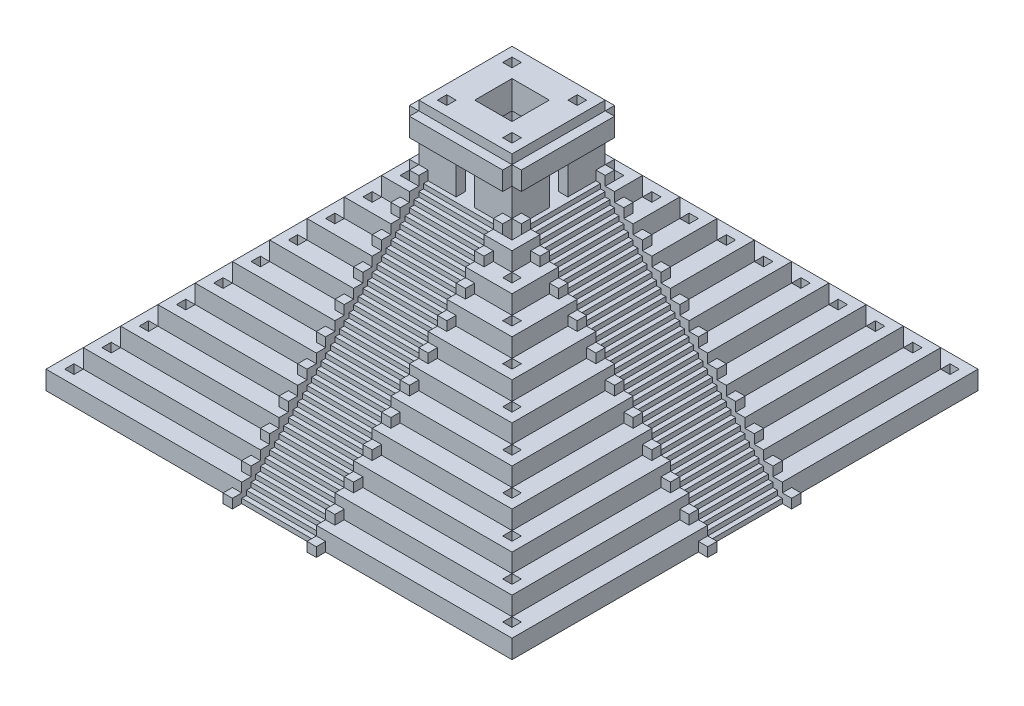
from build123d import *

# Parameters (mm, degrees)
SKIZZE1_W                        = 50
SKIZZE1_H                        = 50
SKIZZE1_W_2                      = 40
SKIZZE1_H_2                      = 40
AUFSATZ_LINEAR_AUSTRAGEN1_DEPTH  = 2
SKIZZE2_W                        = 46
SKIZZE2_H                        = 46
SKIZZE2_W_2                      = 36
SKIZZE2_H_2                      = 36
AUFSATZ_LINEAR_AUSTRAGEN2_DEPTH  = 2
SKIZZE3_W                        = 42
SKIZZE3_H                        = 42
SKIZZE3_W_2                      = 32
SKIZZE3_H_2                      = 32
AUFSATZ_LINEAR_AUSTRAGEN3_DEPTH  = 2
SKIZZE4_W                        = 38
SKIZZE4_H                        = 38
SKIZZE4_W_2                      = 28
SKIZZE4_H_2                      = 28
AUFSATZ_LINEAR_AUSTRAGEN4_DEPTH  = 2
SKIZZE5_W                        = 34
SKIZZE5_H                        = 34
SKIZZE5_W_2                      = 24
SKIZZE5_H_2                      = 24
AUFSATZ_LINEAR_AUSTRAGEN5_DEPTH  = 2
SKIZZE6_W                        = 30
SKIZZE6_H                        = 30
SKIZZE6_W_2                      = 20
SKIZZE6_H_2                      = 20
AUFSATZ_LINEAR_AUSTRAGEN6_DEPTH  = 2
SKIZZE7_W                        = 26
SKIZZE7_H                        = 26
SKIZZE7_W_2                      = 16
SKIZZE7_H_2                      = 16
AUFSATZ_LINEAR_AUSTRAGEN7_DEPTH  = 2
SKIZZE8_W                        = 22
SKIZZE8_H                        = 22
SKIZZE8_W_2                      = 12
SKIZZE8_H_2                      = 12
AUFSATZ_LINEAR_AUSTRAGEN8_DEPTH  = 2
SKIZZE9_W                        = 18
SKIZZE9_H                        = 18
SKIZZE9_W_2                      = 8
SKIZZE9_H_2                      = 8
AUFSATZ_LINEAR_AUSTRAGEN9_DEPTH  = 2
SKIZZE10_W                       = 14
SKIZZE10_H                       = 14
SKIZZE10_W_2                     = 4
SKIZZE10_H_2                     = 4
AUFSATZ_LINEAR_AUSTRAGEN10_DEPTH = 2
AUFSATZ_LINEAR_AUSTRAGEN11_DEPTH = 4
SKIZZE13_W                       = 12
SKIZZE13_H                       = 12
SKIZZE13_W_2                     = 4
SKIZZE13_H_2                     = 4
AUFSATZ_LINEAR_AUSTRAGEN12_DEPTH = 2
SKIZZE13_3_W                     = 10
SKIZZE13_3_H                     = 10
SKIZZE13_3_W_2                   = 4
SKIZZE13_3_H_2                   = 4
AUFSATZ_LINEAR_AUSTRAGEN13_DEPTH = 3
SKIZZE11_W                       = 1
SKIZZE11_H                       = 1
SCHNITT_LINEAR_AUSTRAGEN1_DEPTH  = 45.485952839
AUFSATZ_LINEAR_START             = 4
SKIZZE14_W                       = 1
SKIZZE14_H                       = 1
AUFSATZ_LINEAR_AUSTRAGEN14_DEPTH = 1
SCHNITT_LINEAR_AUSTRAGEN2_DEPTH  = 4
KREISMUSTER1_COUNT               = 4
KREISMUSTER1_START               = 4
KREISMUSTER1_COPY_1_SKETCH_W     = 1
KREISMUSTER1_COPY_1_SKETCH_H     = 1
KREISMUSTER1_COPY_1_DEPTH        = 1
KREISMUSTER1_COPY_2_SKETCH_W     = 1
KREISMUSTER1_COPY_2_SKETCH_H     = 1
KREISMUSTER1_COPY_2_DEPTH        = 1
KREISMUSTER1_COPY_3_SKETCH_W     = 1
KREISMUSTER1_COPY_3_SKETCH_H     = 1
KREISMUSTER1_COPY_3_DEPTH        = 1


with BuildPart() as part:
    # Skizze1 → Aufsatz-Linear austragen1 (new body)
    with BuildSketch(Plane(origin=(0, 0, 0), x_dir=(1, 0, 0), z_dir=(0, 1, 0))):
        Rectangle(SKIZZE1_W, SKIZZE1_H)
        Rectangle(SKIZZE1_W_2, SKIZZE1_H_2, mode=Mode.SUBTRACT)
    extrude(amount=AUFSATZ_LINEAR_AUSTRAGEN1_DEPTH)

    # Skizze2 → Aufsatz-Linear austragen2 (add)
    with BuildSketch(Plane(origin=(0, 2, 0), x_dir=(1, 0, 0), z_dir=(0, 1, 0))):
        Rectangle(SKIZZE2_W, SKIZZE2_H)
        Rectangle(SKIZZE2_W_2, SKIZZE2_H_2, mode=Mode.SUBTRACT)
    extrude(amount=AUFSATZ_LINEAR_AUSTRAGEN2_DEPTH)

    # Skizze3 → Aufsatz-Linear austragen3 (add)
    with BuildSketch(Plane(origin=(0, 4, 0), x_dir=(1, 0, 0), z_dir=(0, 1, 0))):
        Rectangle(SKIZZE3_W, SKIZZE3_H)
        Rectangle(SKIZZE3_W_2, SKIZZE3_H_2, mode=Mode.SUBTRACT)
    extrude(amount=AUFSATZ_LINEAR_AUSTRAGEN3_DEPTH)

    # Skizze4 → Aufsatz-Linear austragen4 (add)
    with BuildSketch(Plane(origin=(0, 6, 0), x_dir=(1, 0, 0), z_dir=(0, 1, 0))):
        Rectangle(SKIZZE4_W, SKIZZE4_H)
        Rectangle(SKIZZE4_W_2, SKIZZE4_H_2, mode=Mode.SUBTRACT)
    extrude(amount=AUFSATZ_LINEAR_AUSTRAGEN4_DEPTH)

    # Skizze5 → Aufsatz-Linear austragen5 (add)
    with BuildSketch(Plane(origin=(0, 8, 0), x_dir=(1, 0, 0), z_dir=(0, 1, 0))):
        Rectangle(SKIZZE5_W, SKIZZE5_H)
        Rectangle(SKIZZE5_W_2, SKIZZE5_H_2, mode=Mode.SUBTRACT)
    extrude(amount=AUFSATZ_LINEAR_AUSTRAGEN5_DEPTH)

    # Skizze6 → Aufsatz-Linear austragen6 (add)
    with BuildSketch(Plane(origin=(0, 10, 0), x_dir=(1, 0, 0), z_dir=(0, 1, 0))):
        Rectangle(SKIZZE6_W, SKIZZE6_H)
        Rectangle(SKIZZE6_W_2, SKIZZE6_H_2, mode=Mode.SUBTRACT)
    extrude(amount=AUFSATZ_LINEAR_AUSTRAGEN6_DEPTH)

    # Skizze7 → Aufsatz-Linear austragen7 (add)
    with BuildSketch(Plane(origin=(0, 12, 0), x_dir=(1, 0, 0), z_dir=(0, 1, 0))):
        Rectangle(SKIZZE7_W, SKIZZE7_H)
        Rectangle(SKIZZE7_W_2, SKIZZE7_H_2, mode=Mode.SUBTRACT)
    extrude(amount=AUFSATZ_LINEAR_AUSTRAGEN7_DEPTH)

    # Skizze8 → Aufsatz-Linear austragen8 (add)
    with BuildSketch(Plane(origin=(0, 14, 0), x_dir=(1, 0, 0), z_dir=(0, 1, 0))):
        Rectangle(SKIZZE8_W, SKIZZE8_H)
        Rectangle(SKIZZE8_W_2, SKIZZE8_H_2, mode=Mode.SUBTRACT)
    extrude(amount=AUFSATZ_LINEAR_AUSTRAGEN8_DEPTH)

    # Skizze9 → Aufsatz-Linear austragen9 (add)
    with BuildSketch(Plane(origin=(0, 16, 0), x_dir=(1, 0, 0), z_dir=(0, 1, 0))):
        Rectangle(SKIZZE9_W, SKIZZE9_H)
        Rectangle(SKIZZE9_W_2, SKIZZE9_H_2, mode=Mode.SUBTRACT)
    extrude(amount=AUFSATZ_LINEAR_AUSTRAGEN9_DEPTH)

    # Skizze10 → Aufsatz-Linear austragen10 (add)
    with BuildSketch(Plane(origin=(0, 18, 0), x_dir=(1, 0, 0), z_dir=(0, 1, 0))):
        Rectangle(SKIZZE10_W, SKIZZE10_H)
        Rectangle(SKIZZE10_W_2, SKIZZE10_H_2, mode=Mode.SUBTRACT)
    extrude(amount=AUFSATZ_LINEAR_AUSTRAGEN10_DEPTH)

    # Skizze12 → Aufsatz-Linear austragen11 (add)
    with BuildSketch(Plane(origin=(0, 20, 0), x_dir=(1, 0, 0), z_dir=(0, 1, 0))):
        Polygon((1, 4), (4, 4), (4, 1), (5, 1), (5, 5), (1, 5), align=None)
        Polygon((-4, 4), (-1, 4), (-1, 5), (-5, 5), (-5, 1), (-4, 1), align=None)
        Polygon((5, -1), (4, -1), (4, -4), (1, -4), (1, -5), (5, -5), align=None)
        Polygon((-4, -4), (-4, -1), (-5, -1), (-5, -5), (-1, -5), (-1, -4), align=None)
    extrude(amount=AUFSATZ_LINEAR_AUSTRAGEN11_DEPTH)

    # Skizze13 → Aufsatz-Linear austragen12 (add)
    with BuildSketch(Plane(origin=(0, 24, 0), x_dir=(1, 0, 0), z_dir=(0, 1, 0))):
        Rectangle(SKIZZE13_W, SKIZZE13_H)
        Rectangle(SKIZZE13_W_2, SKIZZE13_H_2, mode=Mode.SUBTRACT)
    extrude(amount=AUFSATZ_LINEAR_AUSTRAGEN12_DEPTH)

    # Skizze13_3 → Aufsatz-Linear austragen13 (add)
    with BuildSketch(Plane(origin=(0, 24, 0), x_dir=(1, 0, 0), z_dir=(0, 1, 0))):
        Rectangle(SKIZZE13_3_W, SKIZZE13_3_H)
        Rectangle(SKIZZE13_3_W_2, SKIZZE13_3_H_2, mode=Mode.SUBTRACT)
    extrude(amount=AUFSATZ_LINEAR_AUSTRAGEN13_DEPTH)

    # Skizze11 → Schnitt-Linear austragen1 (cut, through all)
    with BuildSketch(Plane(origin=(0, 27, 0), x_dir=(1, 0, 0), z_dir=(0, 1, 0))):
        with Locations((-23.5, 23.5)):
            Rectangle(SKIZZE11_W, SKIZZE11_H)
        with Locations((-21.5, 21.5)):
            Rectangle(SKIZZE11_W, SKIZZE11_H)
        with Locations((-19.5, 19.5)):
            Rectangle(SKIZZE11_W, SKIZZE11_H)
        with Locations((-17.5, 17.5)):
            Rectangle(SKIZZE11_W, SKIZZE11_H)
        with Locations((-15.5, 15.5)):
            Rectangle(SKIZZE11_W, SKIZZE11_H)
        with Locations((-13.5, 13.5)):
            Rectangle(SKIZZE11_W, SKIZZE11_H)
        with Locations((-11.5, 11.5)):
            Rectangle(SKIZZE11_W, SKIZZE11_H)
        with Locations((-9.5, 9.5)):
            Rectangle(SKIZZE11_W, SKIZZE11_H)
        with Locations((-7.5, 7.5)):
            Rectangle(SKIZZE11_W, SKIZZE11_H)
        with Locations((-5.5, 5.5)):
            Rectangle(SKIZZE11_W, SKIZZE11_H)
        with Locations((-3.5, 3.5)):
            Rectangle(SKIZZE11_W, SKIZZE11_H)
    schnitt_linear_austragen1 = extrude(amount=-SCHNITT_LINEAR_AUSTRAGEN1_DEPTH, mode=Mode.SUBTRACT)

    # Skizze14 → Aufsatz-Linear austragen14 (add)
    with BuildSketch(Plane.XY.offset(AUFSATZ_LINEAR_START)):
        with Locations((-5.5, 20.5)):
            Rectangle(SKIZZE14_W, SKIZZE14_H)
        with Locations((-7.5, 18.5)):
            Rectangle(SKIZZE14_W, SKIZZE14_H)
        with Locations((-9.5, 16.5)):
            Rectangle(SKIZZE14_W, SKIZZE14_H)
        with Locations((-11.5, 14.5)):
            Rectangle(SKIZZE14_W, SKIZZE14_H)
        with Locations((-13.5, 12.5)):
            Rectangle(SKIZZE14_W, SKIZZE14_H)
        with Locations((-15.5, 10.5)):
            Rectangle(SKIZZE14_W, SKIZZE14_H)
        with Locations((-17.5, 8.5)):
            Rectangle(SKIZZE14_W, SKIZZE14_H)
        with Locations((-19.5, 6.5)):
            Rectangle(SKIZZE14_W, SKIZZE14_H)
        with Locations((-21.5, 4.5)):
            Rectangle(SKIZZE14_W, SKIZZE14_H)
        with Locations((-23.5, 2.5)):
            Rectangle(SKIZZE14_W, SKIZZE14_H)
        with Locations((-25.5, 0.5)):
            Rectangle(SKIZZE14_W, SKIZZE14_H)
    aufsatz_linear_austragen14 = extrude(amount=AUFSATZ_LINEAR_AUSTRAGEN14_DEPTH)

    # Spiegeln1: Aufsatz-Linear austragen14 across plane
    add(aufsatz_linear_austragen14.mirror(Plane.XY))

    # Skizze15 → Schnitt-Linear austragen2 (cut, symmetric)
    with BuildSketch(Plane.XY):
        Polygon((-25, 0), (-25, 0.5), (-24.5, 0.5), (-24.5, 1), (-24, 1), (-24, 1.5), (-23.5, 1.5), (-23.5, 2), (-23, 2), (-23, 2.5), (-22.5, 2.5), (-22.5, 3), (-22, 3), (-22, 3.5), (-21.5, 3.5), (-21.5, 4), (-21, 4), (-21, 4.5), (-20.5, 4.5), (-20.5, 5), (-20, 5), (-20, 5.5), (-19.5, 5.5), (-19.5, 6), (-19, 6), (-19, 6.5), (-18.5, 6.5), (-18.5, 7), (-18, 7), (-18, 7.5), (-17.5, 7.5), (-17.5, 8), (-17, 8), (-17, 8.5), (-16.5, 8.5), (-16.5, 9), (-16, 9), (-16, 9.5), (-15.5, 9.5), (-15.5, 10), (-15, 10), (-15, 10.5), (-14.5, 10.5), (-14.5, 11), (-14, 11), (-14, 11.5), (-13.5, 11.5), (-13.5, 12), (-13, 12), (-13, 12.5), (-12.5, 12.5), (-12.5, 13), (-12, 13), (-12, 13.5), (-11.5, 13.5), (-11.5, 14), (-11, 14), (-11, 14.5), (-10.5, 14.5), (-10.5, 15), (-10, 15), (-10, 15.5), (-9.5, 15.5), (-9.5, 16), (-9, 16), (-9, 16.5), (-8.5, 16.5), (-8.5, 17), (-8, 17), (-8, 17.5), (-7.5, 17.5), (-7.5, 18), (-7, 18), (-7, 18.5), (-6.5, 18.5), (-6.5, 19), (-6, 19), (-6, 19.5), (-5.5, 19.5), (-5.5, 20), (-5, 20), (-5, 24), (-26, 24), (-26, 0), align=None)
    schnitt_linear_austragen2 = extrude(amount=SCHNITT_LINEAR_AUSTRAGEN2_DEPTH, both=True, mode=Mode.SUBTRACT)

    # Kreismuster1: Schnitt-Linear austragen1, Aufsatz-Linear austragen14, Schnitt-Linear austragen2 ×4 about axis
    kreismuster1_axis = Axis((0, -1.35, 0), (0, 1, 0))
    add([schnitt_linear_austragen1.rotate(kreismuster1_axis, i * 360 / KREISMUSTER1_COUNT) for i in range(1, KREISMUSTER1_COUNT)], mode=Mode.SUBTRACT)
    add([aufsatz_linear_austragen14.rotate(kreismuster1_axis, i * 360 / KREISMUSTER1_COUNT) for i in range(1, KREISMUSTER1_COUNT)])
    add([schnitt_linear_austragen2.rotate(kreismuster1_axis, i * 360 / KREISMUSTER1_COUNT) for i in range(1, KREISMUSTER1_COUNT)], mode=Mode.SUBTRACT)

    # Kreismuster1 copy 1 sketch → Kreismuster1 copy 1 (add)
    with BuildSketch(Plane(origin=(0, 0, 0), x_dir=(0, 0, -1), z_dir=(-1, 0, 0)).offset(KREISMUSTER1_START)):
        with Locations((-5.5, -20.5)):
            Rectangle(KREISMUSTER1_COPY_1_SKETCH_W, KREISMUSTER1_COPY_1_SKETCH_H)
        with Locations((-7.5, -18.5)):
            Rectangle(KREISMUSTER1_COPY_1_SKETCH_W, KREISMUSTER1_COPY_1_SKETCH_H)
        with Locations((-9.5, -16.5)):
            Rectangle(KREISMUSTER1_COPY_1_SKETCH_W, KREISMUSTER1_COPY_1_SKETCH_H)
        with Locations((-11.5, -14.5)):
            Rectangle(KREISMUSTER1_COPY_1_SKETCH_W, KREISMUSTER1_COPY_1_SKETCH_H)
        with Locations((-13.5, -12.5)):
            Rectangle(KREISMUSTER1_COPY_1_SKETCH_W, KREISMUSTER1_COPY_1_SKETCH_H)
        with Locations((-15.5, -10.5)):
            Rectangle(KREISMUSTER1_COPY_1_SKETCH_W, KREISMUSTER1_COPY_1_SKETCH_H)
        with Locations((-17.5, -8.5)):
            Rectangle(KREISMUSTER1_COPY_1_SKETCH_W, KREISMUSTER1_COPY_1_SKETCH_H)
        with Locations((-19.5, -6.5)):
            Rectangle(KREISMUSTER1_COPY_1_SKETCH_W, KREISMUSTER1_COPY_1_SKETCH_H)
        with Locations((-21.5, -4.5)):
            Rectangle(KREISMUSTER1_COPY_1_SKETCH_W, KREISMUSTER1_COPY_1_SKETCH_H)
        with Locations((-23.5, -2.5)):
            Rectangle(KREISMUSTER1_COPY_1_SKETCH_W, KREISMUSTER1_COPY_1_SKETCH_H)
        with Locations((-25.5, -0.5)):
            Rectangle(KREISMUSTER1_COPY_1_SKETCH_W, KREISMUSTER1_COPY_1_SKETCH_H)
    extrude(amount=KREISMUSTER1_COPY_1_DEPTH)

    # Kreismuster1 copy 2 sketch → Kreismuster1 copy 2 (add)
    with BuildSketch(Plane(origin=(0, 0, 0), x_dir=(-1, 0, 0), z_dir=(0, 0, 1)).offset(KREISMUSTER1_START)):
        with Locations((-5.5, -20.5)):
            Rectangle(KREISMUSTER1_COPY_2_SKETCH_W, KREISMUSTER1_COPY_2_SKETCH_H)
        with Locations((-7.5, -18.5)):
            Rectangle(KREISMUSTER1_COPY_2_SKETCH_W, KREISMUSTER1_COPY_2_SKETCH_H)
        with Locations((-9.5, -16.5)):
            Rectangle(KREISMUSTER1_COPY_2_SKETCH_W, KREISMUSTER1_COPY_2_SKETCH_H)
        with Locations((-11.5, -14.5)):
            Rectangle(KREISMUSTER1_COPY_2_SKETCH_W, KREISMUSTER1_COPY_2_SKETCH_H)
        with Locations((-13.5, -12.5)):
            Rectangle(KREISMUSTER1_COPY_2_SKETCH_W, KREISMUSTER1_COPY_2_SKETCH_H)
        with Locations((-15.5, -10.5)):
            Rectangle(KREISMUSTER1_COPY_2_SKETCH_W, KREISMUSTER1_COPY_2_SKETCH_H)
        with Locations((-17.5, -8.5)):
            Rectangle(KREISMUSTER1_COPY_2_SKETCH_W, KREISMUSTER1_COPY_2_SKETCH_H)
        with Locations((-19.5, -6.5)):
            Rectangle(KREISMUSTER1_COPY_2_SKETCH_W, KREISMUSTER1_COPY_2_SKETCH_H)
        with Locations((-21.5, -4.5)):
            Rectangle(KREISMUSTER1_COPY_2_SKETCH_W, KREISMUSTER1_COPY_2_SKETCH_H)
        with Locations((-23.5, -2.5)):
            Rectangle(KREISMUSTER1_COPY_2_SKETCH_W, KREISMUSTER1_COPY_2_SKETCH_H)
        with Locations((-25.5, -0.5)):
            Rectangle(KREISMUSTER1_COPY_2_SKETCH_W, KREISMUSTER1_COPY_2_SKETCH_H)
    extrude(amount=KREISMUSTER1_COPY_2_DEPTH)

    # Kreismuster1 copy 3 sketch → Kreismuster1 copy 3 (add)
    with BuildSketch(Plane(origin=(0, 0, 0), x_dir=(0, 0, 1), z_dir=(1, 0, 0)).offset(KREISMUSTER1_START)):
        with Locations((-5.5, -20.5)):
            Rectangle(KREISMUSTER1_COPY_3_SKETCH_W, KREISMUSTER1_COPY_3_SKETCH_H)
        with Locations((-7.5, -18.5)):
            Rectangle(KREISMUSTER1_COPY_3_SKETCH_W, KREISMUSTER1_COPY_3_SKETCH_H)
        with Locations((-9.5, -16.5)):
            Rectangle(KREISMUSTER1_COPY_3_SKETCH_W, KREISMUSTER1_COPY_3_SKETCH_H)
        with Locations((-11.5, -14.5)):
            Rectangle(KREISMUSTER1_COPY_3_SKETCH_W, KREISMUSTER1_COPY_3_SKETCH_H)
        with Locations((-13.5, -12.5)):
            Rectangle(KREISMUSTER1_COPY_3_SKETCH_W, KREISMUSTER1_COPY_3_SKETCH_H)
        with Locations((-15.5, -10.5)):
            Rectangle(KREISMUSTER1_COPY_3_SKETCH_W, KREISMUSTER1_COPY_3_SKETCH_H)
        with Locations((-17.5, -8.5)):
            Rectangle(KREISMUSTER1_COPY_3_SKETCH_W, KREISMUSTER1_COPY_3_SKETCH_H)
        with Locations((-19.5, -6.5)):
            Rectangle(KREISMUSTER1_COPY_3_SKETCH_W, KREISMUSTER1_COPY_3_SKETCH_H)
        with Locations((-21.5, -4.5)):
            Rectangle(KREISMUSTER1_COPY_3_SKETCH_W, KREISMUSTER1_COPY_3_SKETCH_H)
        with Locations((-23.5, -2.5)):
            Rectangle(KREISMUSTER1_COPY_3_SKETCH_W, KREISMUSTER1_COPY_3_SKETCH_H)
        with Locations((-25.5, -0.5)):
            Rectangle(KREISMUSTER1_COPY_3_SKETCH_W, KREISMUSTER1_COPY_3_SKETCH_H)
    extrude(amount=KREISMUSTER1_COPY_3_DEPTH)


solid = part.part
